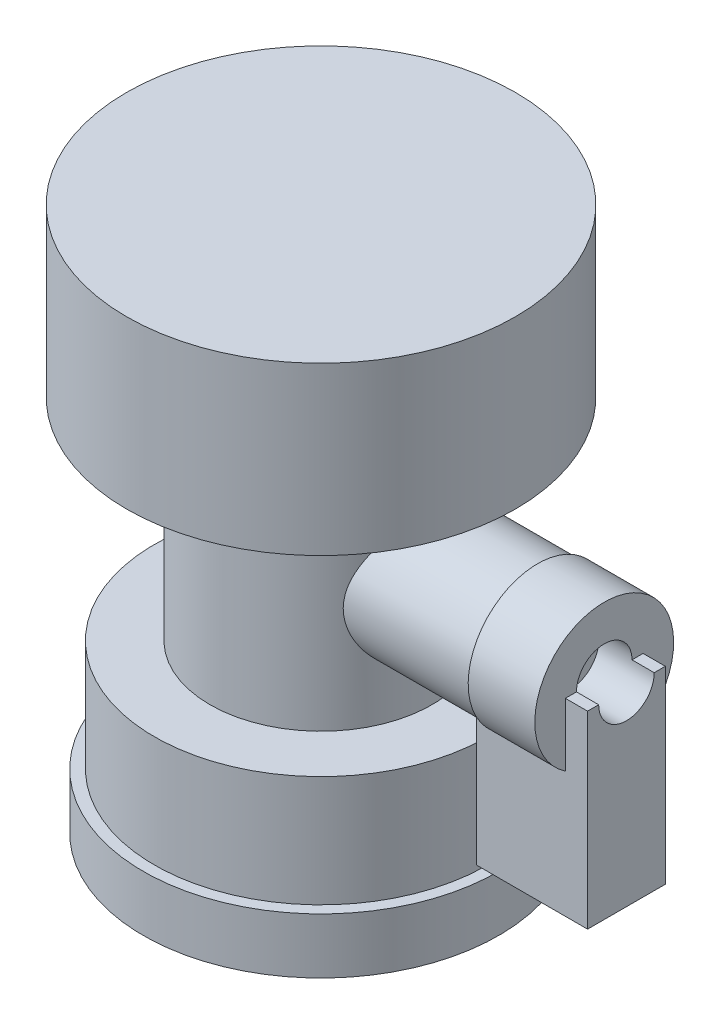
from build123d import *

# Parameters (mm, degrees)
SKETCH1_R                      = 10
BOSS_EXTRUDE1_DEPTH            = 19
SKETCH2_R                      = 6
BOSS_EXTRUDE2_DEPTH            = 19.5
SKETCH7_R                      = 15
BOSS_EXTRUDE9_DEPTH            = 10
SKETCH9_R                      = 16
BOSS_EXTRUDE10_DEPTH           = 5
SKETCH10_R                     = 17.5
BOSS_EXTRUDE11_DEPTH           = 15
SKETCH11_R                     = 6.25
BOSS_EXTRUDE12_DEPTH           = 6
SKETCH12_W                     = 10
SKETCH12_H                     = 7
BOSS_EXTRUDE13_DEPTH           = 10
BOSS_EXTRUDE13_DEPTH_BACK      = 7
SKETCH13_R                     = 2.5
CUT_EXTRUDE1_DEPTH             = 3
CUT_EXTRUDE1_DIRECTION_2_REACH = 4


with BuildPart() as part:
    # Sketch1 → Boss-Extrude1 (new body)
    with BuildSketch(Plane(origin=(0, 0, 0), x_dir=(1, 0, 0), z_dir=(0, 1, 0))):
        Circle(SKETCH1_R)
    extrude(amount=BOSS_EXTRUDE1_DEPTH)

    # Sketch2 → Boss-Extrude2 (add)
    with BuildSketch(Plane(origin=(0, 0, 0), x_dir=(0, 0, -1), z_dir=(1, 0, 0))):
        with Locations((0, 9.5)):
            Circle(SKETCH2_R)
    extrude(amount=BOSS_EXTRUDE2_DEPTH)

    # Sketch7 → Boss-Extrude9 (add)
    with BuildSketch(Plane.XZ):
        Circle(SKETCH7_R)
    extrude(amount=BOSS_EXTRUDE9_DEPTH)

    # Sketch9 → Boss-Extrude10 (add)
    with BuildSketch(Plane.XZ.offset(10)):
        Circle(SKETCH9_R)
    extrude(amount=BOSS_EXTRUDE10_DEPTH)

    # Sketch10 → Boss-Extrude11 (add)
    with BuildSketch(Plane(origin=(0, 19, 0), x_dir=(1, 0, 0), z_dir=(0, 1, 0))):
        Circle(SKETCH10_R)
    extrude(amount=BOSS_EXTRUDE11_DEPTH)

    # Sketch11 → Boss-Extrude12 (add)
    with BuildSketch(Plane(origin=(19.5, 0, 0), x_dir=(0, 0, -1), z_dir=(1, 0, 0))):
        with Locations((0, 9.5)):
            Circle(SKETCH11_R)
    extrude(amount=BOSS_EXTRUDE12_DEPTH)

    # Sketch12 → Boss-Extrude13 (add, two sides)
    with BuildSketch(Plane(origin=(0, 0, 0), x_dir=(1, 0, 0), z_dir=(0, 1, 0))) as boss_extrude13_sk:
        with Locations((22.5, 0)):
            Rectangle(SKETCH12_W, SKETCH12_H)
    extrude(amount=BOSS_EXTRUDE13_DEPTH)
    extrude(boss_extrude13_sk.sketch, amount=-BOSS_EXTRUDE13_DEPTH_BACK)

    # Sketch13 → Cut-Extrude1 (cut)
    with BuildSketch(Plane(origin=(25.5, 0, 0), x_dir=(0, 0, -1), z_dir=(1, 0, 0))):
        with Locations((0, 10)):
            Circle(SKETCH13_R)
    extrude(amount=-CUT_EXTRUDE1_DEPTH, mode=Mode.SUBTRACT)

    # Sketch13 → Cut-Extrude1 direction 2 (cut, up to next)
    with BuildSketch(Plane(origin=(25.5, 0, 0), x_dir=(0, 0, -1), z_dir=(1, 0, 0)), mode=Mode.PRIVATE) as cut_extrude1_direction_2_sk1:
        with Locations((0, 10)):
            Circle(SKETCH13_R)
    cut_extrude1_direction_2_tool1 = extrude(cut_extrude1_direction_2_sk1.sketch, amount=CUT_EXTRUDE1_DIRECTION_2_REACH, mode=Mode.PRIVATE) & part.part
    add(cut_extrude1_direction_2_tool1.solids().sort_by_distance((25.5, 10, 0))[0], mode=Mode.SUBTRACT)


solid = part.part
